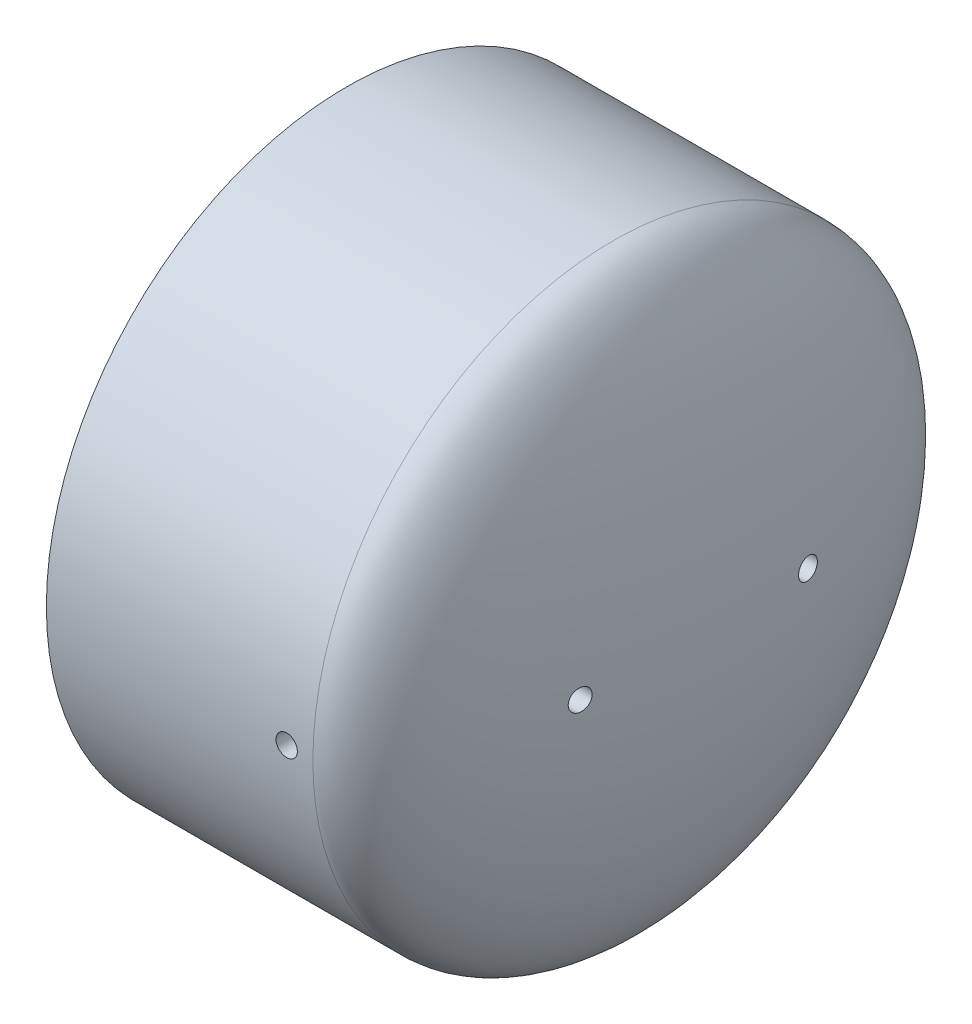
from build123d import *

# Parameters (mm, degrees)
SKETCH2_R               = 2.38125
CUT_EXTRUDE3_DEPTH      = 79.994
SKETCH3_R               = 2.38125
CUT_EXTRUDE4_DEPTH      = 67.9290001
CUT_EXTRUDE4_DEPTH_BACK = 67.9290001


with BuildPart() as part:
    # Sketch1 → Revolve1 (revolve)
    with BuildSketch(Plane.XY):
        with BuildLine():
            Line((-78.994, -66.929), (-19.558, -66.929))
            add(Edge.make_bspline(
                [(-19.558, -66.929), (0, -66.929), (0, 0)],
                knots=[3.141592654, 3.141592654, 3.141592654, 4.71238898, 4.71238898, 4.71238898], degree=2, weights=[1, 0.707106781, 1]))
            Line((0, 0), (-9.8933, 0))
            add(Edge.make_bspline(
                [(-19.558, -57.0357), (-9.8933, -57.0357), (-9.8933, 0)],
                knots=[0, 0, 0, 1.570796327, 1.570796327, 1.570796327], degree=2, weights=[1, 0.707106781, 1]))
            Line((-19.558, -57.0357), (-78.994, -57.3786))
            Line((-78.994, -57.3786), (-78.994, -66.929))
        make_face()
    revolve(axis=Axis((-78.994, 0, 0), (1, 0, 0)))

    # Sketch2 → Cut-Extrude3 (cut, through all)
    with BuildSketch(Plane(origin=(0, 0, 0), x_dir=(0, 0, -1), z_dir=(1, 0, 0))):
        with Locations((-25.4, 0)):
            Circle(SKETCH2_R)
        with Locations((25.4, 0)):
            Circle(SKETCH2_R)
    extrude(amount=-CUT_EXTRUDE3_DEPTH, mode=Mode.SUBTRACT)

    # Sketch3 → Cut-Extrude4 (cut, two sides)
    with BuildSketch(Plane.XY) as cut_extrude4_sk:
        with Locations((-25.4, 0)):
            Circle(SKETCH3_R)
    extrude(amount=CUT_EXTRUDE4_DEPTH, mode=Mode.SUBTRACT)
    extrude(cut_extrude4_sk.sketch, amount=-CUT_EXTRUDE4_DEPTH_BACK, mode=Mode.SUBTRACT)


solid = part.part
